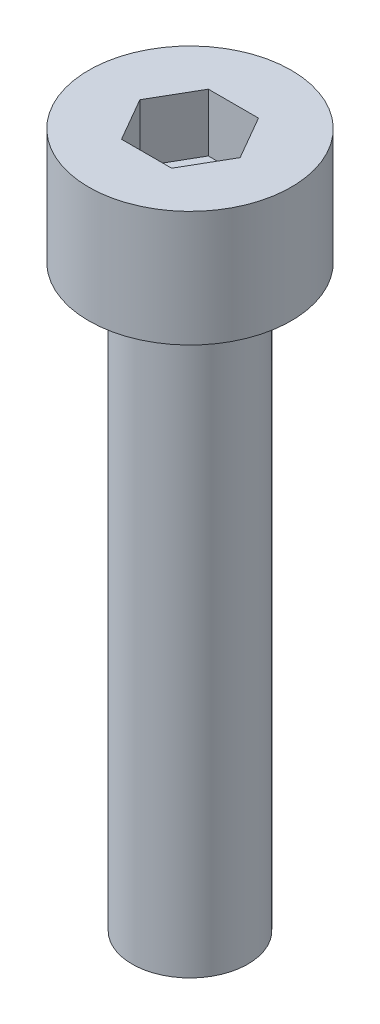
from build123d import *

# Parameters (mm, degrees)
SKETCH_1_R            = 3.5
EXTRUDE_246_DEPTH     = 4
CUT_EXTRUDE_376_DEPTH = 2
SKETCH_3_R            = 2
EXTRUDE_477_DEPTH     = 20


with BuildPart() as part:
    # 草图1 → Extrude 246 (new body)
    with BuildSketch(Plane(origin=(0, 0, 0), x_dir=(1, 0, 0), z_dir=(0, 1, 0))):
        Circle(SKETCH_1_R)
    extrude(amount=EXTRUDE_246_DEPTH)

    # 草图2 → Cut-Extrude 376 (cut)
    with BuildSketch(Plane(origin=(0, 4, 0), x_dir=(1, 0, 0), z_dir=(0, 1, 0))):
        Polygon((1.732050808, 0), (0.866025404, 1.5), (-0.866025404, 1.5), (-1.732050808, 0), (-0.866025404, -1.5), (0.866025404, -1.5), align=None)
    extrude(amount=-CUT_EXTRUDE_376_DEPTH, mode=Mode.SUBTRACT)

    # 草图3 → Extrude 477 (add)
    with BuildSketch(Plane.XZ):
        Circle(SKETCH_3_R)
    extrude(amount=EXTRUDE_477_DEPTH)


solid = part.part
